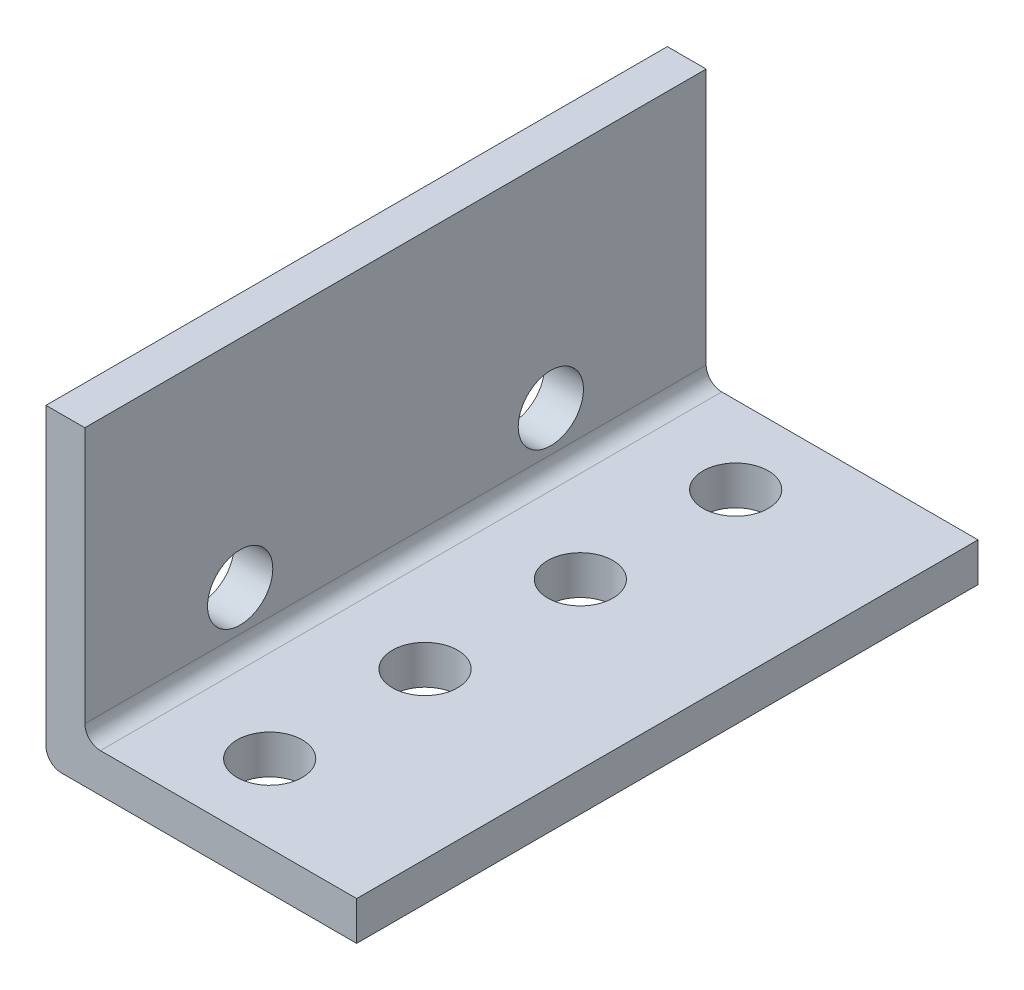
from build123d import *

# Parameters (mm, degrees)
BOSS_EXTRUDE1_DEPTH     = 50.8
SKETCH2_R               = 2.667
CUT_EXTRUDE1_DEPTH      = 23.225
CUT_EXTRUDE1_DEPTH_BACK = 4.175
SKETCH3_R               = 2.667
CUT_EXTRUDE2_DEPTH      = 3.175
FILLET1_R               = 1.27
FILLET2_R               = 1.27


with BuildPart() as part:
    # Sketch1 → Boss-Extrude1 (new body)
    with BuildSketch(Plane.XY):
        Polygon((0, -22.225), (22.225, -22.225), (22.225, -25.4), (-3.175, -25.4), (-3.175, 0), (0, 0), align=None)
    extrude(amount=BOSS_EXTRUDE1_DEPTH)

    # Sketch2 → Cut-Extrude1 (cut, two sides)
    with BuildSketch(Plane(origin=(0, 0, 0), x_dir=(0, 0, -1), z_dir=(1, 0, 0))) as cut_extrude1_sk:
        with Locations((-38.1, -17.653)):
            Circle(SKETCH2_R)
        with Locations((-12.7, -17.653)):
            Circle(SKETCH2_R)
    extrude(amount=CUT_EXTRUDE1_DEPTH, mode=Mode.SUBTRACT)
    extrude(cut_extrude1_sk.sketch, amount=-CUT_EXTRUDE1_DEPTH_BACK, mode=Mode.SUBTRACT)

    # Sketch3 → Cut-Extrude2 (cut)
    with BuildSketch(Plane(origin=(0, -22.225, 0), x_dir=(1, 0, 0), z_dir=(0, 1, 0))):
        with Locations((8.763, -44.45)):
            Circle(SKETCH3_R)
        with Locations((8.763, -31.75)):
            Circle(SKETCH3_R)
        with Locations((8.763, -19.05)):
            Circle(SKETCH3_R)
        with Locations((8.763, -6.35)):
            Circle(SKETCH3_R)
    extrude(amount=-CUT_EXTRUDE2_DEPTH, mode=Mode.SUBTRACT)

    # Fillet1
    fillet1_edges = [part.edges().sort_by_distance(p)[0] for p in [
        (0, -22.225, 25.4),
    ]]
    fillet(fillet1_edges, radius=FILLET1_R)

    # Fillet2
    fillet2_edges = [part.edges().sort_by_distance(p)[0] for p in [
        (-3.175, -25.4, 25.4),
    ]]
    fillet(fillet2_edges, radius=FILLET2_R)


solid = part.part
